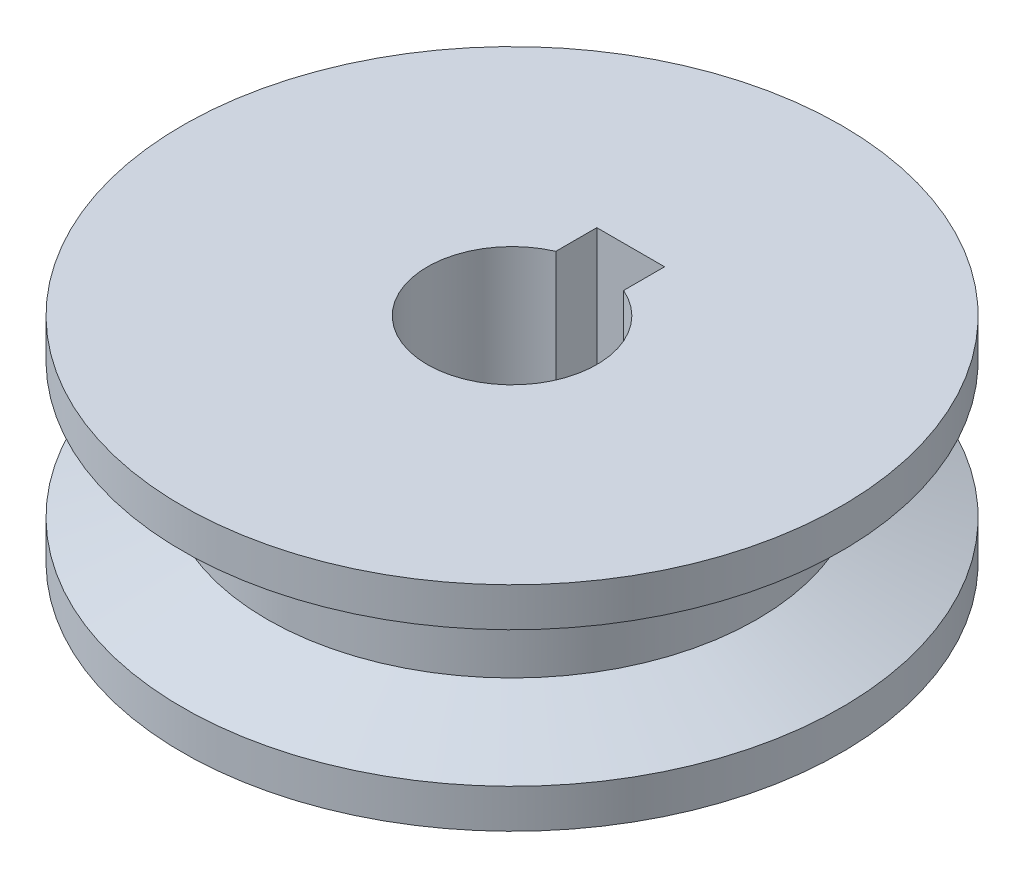
from build123d import *

# Parameters (mm, degrees)
CORTAR_EXTRUIR1_DEPTH = 21


with BuildPart() as part:
    # Croquis1 → Revolución2 (revolve)
    with BuildSketch(Plane.XY):
        Polygon((7.9375, 0), (7.9375, 20), (30.875, 20), (30.875, 16.35), (22.9375, 13.175), (22.9375, 6.825), (30.875, 3.65), (30.875, 0), align=None)
    revolve(axis=Axis((0, 0, 0), (0, 1, 0)))

    # Croquis2 → Cortar-Extruir1 (cut, through all)
    with BuildSketch(Plane(origin=(0, 20, 0), x_dir=(1, 0, 0), z_dir=(0, 1, 0))):
        with BuildLine():
            Line((-3.175, 11.1125), (-3.175, 7.274838916))
            ThreePointArc((-3.175, 7.274838916), (0, 7.9375), (3.175, 7.274838916))
            Line((3.175, 7.274838916), (3.175, 11.1125))
            Line((3.175, 11.1125), (-3.175, 11.1125))
        make_face()
    extrude(amount=-CORTAR_EXTRUIR1_DEPTH, mode=Mode.SUBTRACT)


solid = part.part
